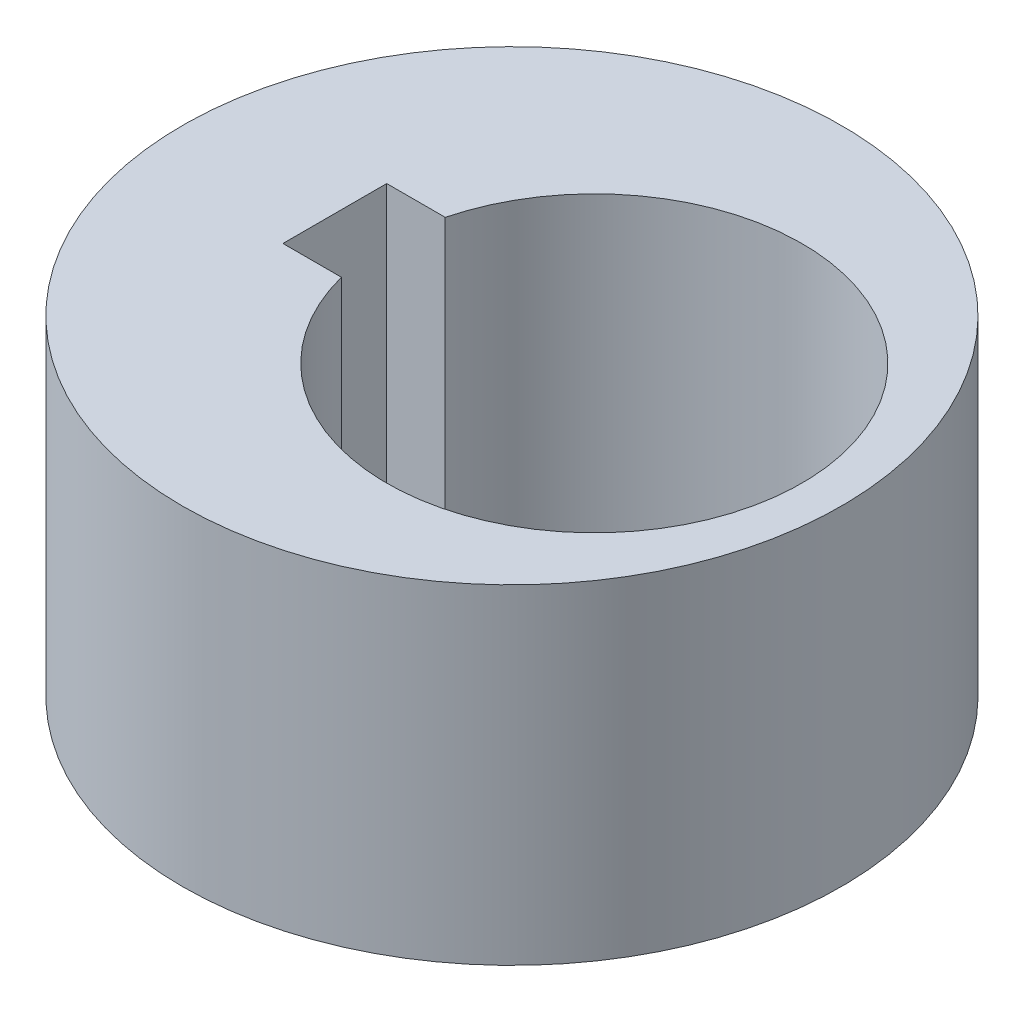
from build123d import *

# Parameters (mm, degrees)
SKETCH1_R           = 6.35
BOSS_EXTRUDE1_DEPTH = 6.35
SKETCH2_R           = 4
CUT_EXTRUDE1_DEPTH  = 6.35
SKETCH3_W           = 2
SKETCH3_H           = 2
CUT_EXTRUDE2_DEPTH  = 6.35


with BuildPart() as part:
    # Sketch1 → Boss-Extrude1 (new body)
    with BuildSketch(Plane(origin=(0, 0, 0), x_dir=(1, 0, 0), z_dir=(0, 1, 0))):
        Circle(SKETCH1_R)
    extrude(amount=BOSS_EXTRUDE1_DEPTH)

    # Sketch2 → Cut-Extrude1 (cut)
    with BuildSketch(Plane(origin=(0, 6.35, 0), x_dir=(1, 0, 0), z_dir=(0, 1, 0))):
        with Locations((1.5875, 0)):
            Circle(SKETCH2_R)
    extrude(amount=-CUT_EXTRUDE1_DEPTH, mode=Mode.SUBTRACT)

    # Sketch3 → Cut-Extrude2 (cut)
    with BuildSketch(Plane(origin=(0, 6.35, 0), x_dir=(1, 0, 0), z_dir=(0, 1, 0))):
        with Locations((-2.4125, 0)):
            Rectangle(SKETCH3_W, SKETCH3_H)
    extrude(amount=-CUT_EXTRUDE2_DEPTH, mode=Mode.SUBTRACT)


solid = part.part
